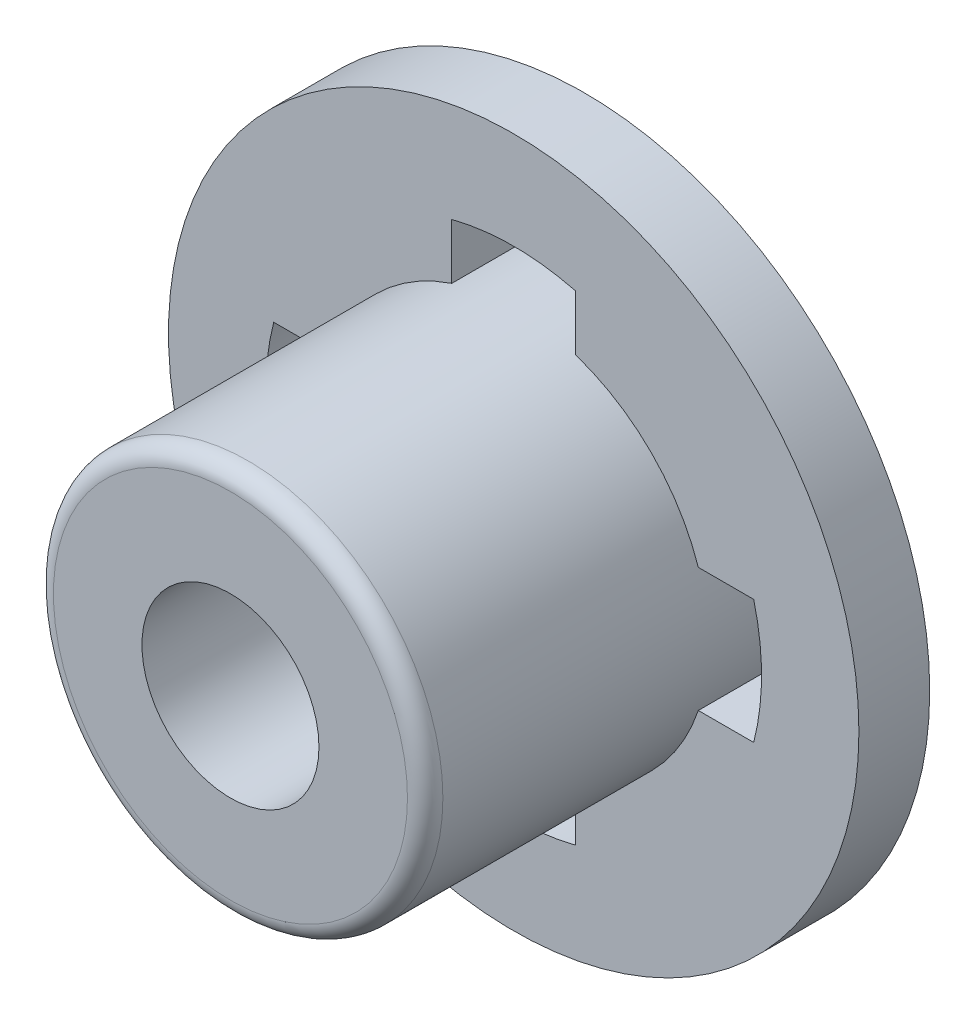
from build123d import *

# Parameters (mm, degrees)
SKETCH_1_R          = 3.9
SKETCH_1_R_2        = 2.2
SKETCH_1_R_3        = 1
EXTRUDE_1_DEPTH     = 0.8
SKETCH_1_4_R        = 2.2
SKETCH_1_4_R_2      = 1
EXTRUDE_2_DEPTH     = 3.2
FILLET_1_R          = 0.2
SKETCH_2_R          = 1.15
CUT_EXTRUDE_1_DEPTH = 0.5
CUT_EXTRUDE_2_REACH = 8.813


with BuildPart() as part:
    # Sketch 1 → Extrude 1 (new body)
    with BuildSketch(Plane.XY):
        Circle(SKETCH_1_R)
        Circle(SKETCH_1_R_2, mode=Mode.SUBTRACT)
        Circle(SKETCH_1_R_2)
        Circle(SKETCH_1_R_3, mode=Mode.SUBTRACT)
    extrude(amount=-EXTRUDE_1_DEPTH)

    # Sketch 1_4 → Extrude 2 (add)
    with BuildSketch(Plane.XY):
        Circle(SKETCH_1_4_R)
        Circle(SKETCH_1_4_R_2, mode=Mode.SUBTRACT)
    extrude(amount=EXTRUDE_2_DEPTH)

    # Fillet 1
    fillet_1_edges = [part.edges().sort_by_distance(p)[0] for p in [
        (-2.2, 0, 3.2),
    ]]
    fillet(fillet_1_edges, radius=FILLET_1_R)

    # Sketch 2 → Cut-Extrude 1 (cut)
    with BuildSketch(Plane(origin=(0, 0, -0.8), x_dir=(-1, 0, 0), z_dir=(0, 0, -1))):
        Circle(SKETCH_2_R)
    extrude(amount=-CUT_EXTRUDE_1_DEPTH, mode=Mode.SUBTRACT)

    # Sketch 3 → Cut-Extrude 2 (cut, up to next)
    with BuildSketch(Plane(origin=(0, 0, -0.8), x_dir=(-1, 0, 0), z_dir=(0, 0, -1)), mode=Mode.PRIVATE) as cut_extrude_2_sk1:
        with BuildLine():
            Line((-0.7, -2.085665361), (-0.7, -2.711088342))
            ThreePointArc((-0.7, -2.711088342), (0, -2.8), (0.7, -2.711088342))
            Line((0.7, -2.711088342), (0.7, -2.085665361))
            ThreePointArc((0.7, -2.085665361), (0, -2.2), (-0.7, -2.085665361))
        make_face()
    cut_extrude_2_tool1 = extrude(cut_extrude_2_sk1.sketch, amount=-CUT_EXTRUDE_2_REACH, mode=Mode.PRIVATE) & part.part
    # Sketch 3 → Cut-Extrude 2 (cut, up to next)
    with BuildSketch(Plane(origin=(0, 0, -0.8), x_dir=(-1, 0, 0), z_dir=(0, 0, -1)), mode=Mode.PRIVATE) as cut_extrude_2_sk2:
        with BuildLine():
            ThreePointArc((0.7, 2.711088342), (0, 2.8), (-0.7, 2.711088342))
            Line((-0.7, 2.711088342), (-0.7, 2.085665361))
            ThreePointArc((-0.7, 2.085665361), (0, 2.2), (0.7, 2.085665361))
            Line((0.7, 2.085665361), (0.7, 2.711088342))
        make_face()
    cut_extrude_2_tool2 = extrude(cut_extrude_2_sk2.sketch, amount=-CUT_EXTRUDE_2_REACH, mode=Mode.PRIVATE) & part.part
    # Sketch 3 → Cut-Extrude 2 (cut, up to next)
    with BuildSketch(Plane(origin=(0, 0, -0.8), x_dir=(-1, 0, 0), z_dir=(0, 0, -1)), mode=Mode.PRIVATE) as cut_extrude_2_sk3:
        with BuildLine():
            Line((-0.7, -2.085665361), (-0.7, -2.711088342))
            ThreePointArc((-0.7, -2.711088342), (0, -2.8), (0.7, -2.711088342))
            Line((0.7, -2.711088342), (0.7, -2.085665361))
            ThreePointArc((0.7, -2.085665361), (0, -2.2), (-0.7, -2.085665361))
        make_face()
    cut_extrude_2_tool3 = extrude(cut_extrude_2_sk3.sketch, amount=-CUT_EXTRUDE_2_REACH, mode=Mode.PRIVATE) & part.part
    # Sketch 3 → Cut-Extrude 2 (cut, up to next)
    with BuildSketch(Plane(origin=(0, 0, -0.8), x_dir=(-1, 0, 0), z_dir=(0, 0, -1)), mode=Mode.PRIVATE) as cut_extrude_2_sk4:
        with BuildLine():
            ThreePointArc((0.7, 2.711088342), (0, 2.8), (-0.7, 2.711088342))
            Line((-0.7, 2.711088342), (-0.7, 2.085665361))
            ThreePointArc((-0.7, 2.085665361), (0, 2.2), (0.7, 2.085665361))
            Line((0.7, 2.085665361), (0.7, 2.711088342))
        make_face()
    cut_extrude_2_tool4 = extrude(cut_extrude_2_sk4.sketch, amount=-CUT_EXTRUDE_2_REACH, mode=Mode.PRIVATE) & part.part
    # Sketch 3 → Cut-Extrude 2 (cut, up to next)
    with BuildSketch(Plane(origin=(0, 0, -0.8), x_dir=(-1, 0, 0), z_dir=(0, 0, -1)), mode=Mode.PRIVATE) as cut_extrude_2_sk5:
        with BuildLine():
            ThreePointArc((-2.711088342, 0.7), (-2.8, 0), (-2.711088342, -0.7))
            Line((-2.711088342, -0.7), (-2.085665361, -0.7))
            ThreePointArc((-2.085665361, -0.7), (-2.2, 0), (-2.085665361, 0.7))
            Line((-2.085665361, 0.7), (-2.711088342, 0.7))
        make_face()
    cut_extrude_2_tool5 = extrude(cut_extrude_2_sk5.sketch, amount=-CUT_EXTRUDE_2_REACH, mode=Mode.PRIVATE) & part.part
    # Sketch 3 → Cut-Extrude 2 (cut, up to next)
    with BuildSketch(Plane(origin=(0, 0, -0.8), x_dir=(-1, 0, 0), z_dir=(0, 0, -1)), mode=Mode.PRIVATE) as cut_extrude_2_sk6:
        with BuildLine():
            Line((2.085665361, -0.7), (2.711088342, -0.7))
            ThreePointArc((2.711088342, -0.7), (2.77768315, -0.352812019), (2.8, 0))
            ThreePointArc((2.8, 0), (2.77768315, 0.352812019), (2.711088342, 0.7))
            Line((2.711088342, 0.7), (2.085665361, 0.7))
            ThreePointArc((2.085665361, 0.7), (2.1712282, 0.354637988), (2.2, 0))
            ThreePointArc((2.2, 0), (2.1712282, -0.354637988), (2.085665361, -0.7))
        make_face()
    cut_extrude_2_tool6 = extrude(cut_extrude_2_sk6.sketch, amount=-CUT_EXTRUDE_2_REACH, mode=Mode.PRIVATE) & part.part
    # Sketch 3 → Cut-Extrude 2 (cut, up to next)
    with BuildSketch(Plane(origin=(0, 0, -0.8), x_dir=(-1, 0, 0), z_dir=(0, 0, -1)), mode=Mode.PRIVATE) as cut_extrude_2_sk7:
        with BuildLine():
            ThreePointArc((-2.711088342, 0.7), (-2.8, 0), (-2.711088342, -0.7))
            Line((-2.711088342, -0.7), (-2.085665361, -0.7))
            ThreePointArc((-2.085665361, -0.7), (-2.2, 0), (-2.085665361, 0.7))
            Line((-2.085665361, 0.7), (-2.711088342, 0.7))
        make_face()
    cut_extrude_2_tool7 = extrude(cut_extrude_2_sk7.sketch, amount=-CUT_EXTRUDE_2_REACH, mode=Mode.PRIVATE) & part.part
    # Sketch 3 → Cut-Extrude 2 (cut, up to next)
    with BuildSketch(Plane(origin=(0, 0, -0.8), x_dir=(-1, 0, 0), z_dir=(0, 0, -1)), mode=Mode.PRIVATE) as cut_extrude_2_sk8:
        with BuildLine():
            Line((2.085665361, -0.7), (2.711088342, -0.7))
            ThreePointArc((2.711088342, -0.7), (2.77768315, -0.352812019), (2.8, 0))
            ThreePointArc((2.8, 0), (2.77768315, 0.352812019), (2.711088342, 0.7))
            Line((2.711088342, 0.7), (2.085665361, 0.7))
            ThreePointArc((2.085665361, 0.7), (2.1712282, 0.354637988), (2.2, 0))
            ThreePointArc((2.2, 0), (2.1712282, -0.354637988), (2.085665361, -0.7))
        make_face()
    cut_extrude_2_tool8 = extrude(cut_extrude_2_sk8.sketch, amount=-CUT_EXTRUDE_2_REACH, mode=Mode.PRIVATE) & part.part
    add(cut_extrude_2_tool1.solids().sort_by_distance((0, -2.466051, -0.8))[0], mode=Mode.SUBTRACT)
    add(cut_extrude_2_tool2.solids().sort_by_distance((0, 2.466051, -0.8))[0], mode=Mode.SUBTRACT)
    add(cut_extrude_2_tool3.solids().sort_by_distance((0, -2.466051, -0.8))[0], mode=Mode.SUBTRACT)
    add(cut_extrude_2_tool4.solids().sort_by_distance((0, 2.466051, -0.8))[0], mode=Mode.SUBTRACT)
    add(cut_extrude_2_tool5.solids().sort_by_distance((2.466051, 0, -0.8))[0], mode=Mode.SUBTRACT)
    add(cut_extrude_2_tool6.solids().sort_by_distance((-2.466051, 0, -0.8))[0], mode=Mode.SUBTRACT)
    add(cut_extrude_2_tool7.solids().sort_by_distance((2.466051, 0, -0.8))[0], mode=Mode.SUBTRACT)
    add(cut_extrude_2_tool8.solids().sort_by_distance((-2.466051, 0, -0.8))[0], mode=Mode.SUBTRACT)


solid = part.part
